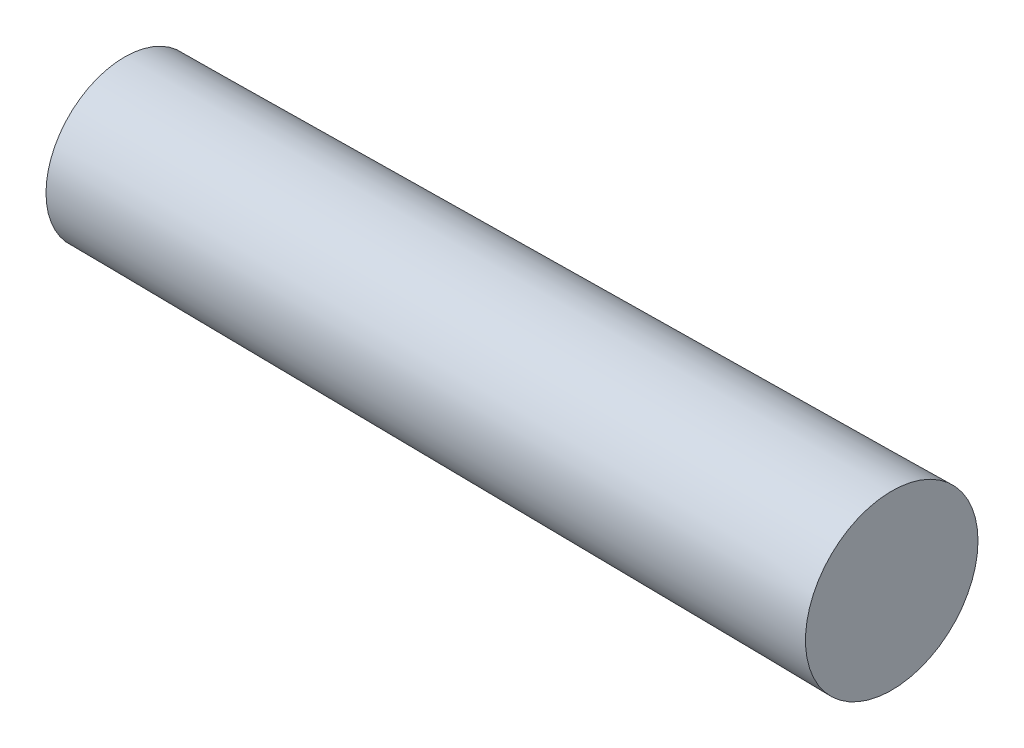
from build123d import *


with BuildPart() as part:
    # Sketch1 → Base-Revolve (revolve)
    with BuildSketch(Plane.XY):
        with BuildLine():
            Line((0.12, 0.5), (5.88, 0.5576))
            ThreePointArc((5.88, 0.5576), (5.96966046, 0.285183169), (6, 0))
            Line((6, 0), (0, 0))
            ThreePointArc((0, 0), (0.030419989, 0.257099203), (0.12, 0.5))
        make_face()
    revolve(axis=Axis((0, 0, 0), (1, 0, 0)))

    # SurfaceCut1
    split(bisect_by=Plane(origin=(5, 0, 0), x_dir=(0, 0, -1), z_dir=(1, 0, 0)), keep=Keep.BOTTOM)


solid = part.part
